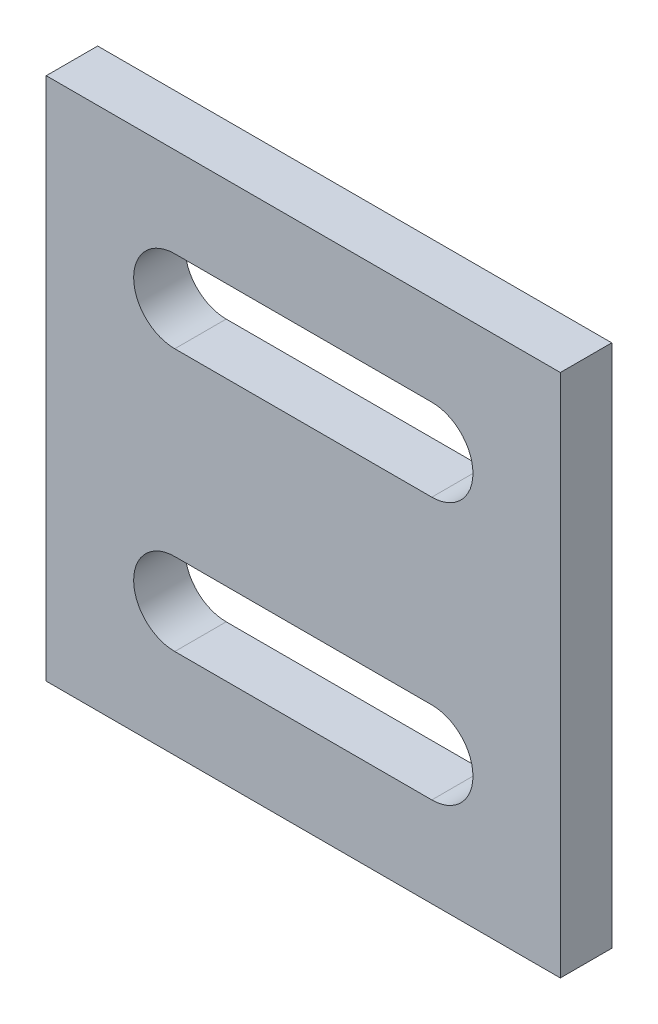
from build123d import *

# Parameters (mm, degrees)
SKETCH_1_W      = 20
SKETCH_1_H      = 20.4
EXTRUDE_1_DEPTH = 2


with BuildPart() as part:
    # 草图1 → 凸台-拉伸1 (new body)
    with BuildSketch(Plane.XY):
        with Locations((-8.175518001, 8.140962295)):
            Rectangle(SKETCH_1_W, SKETCH_1_H)
        with BuildLine():
            Line((-13.175518001, 14.840962295), (-3.175518001, 14.840962295))
            ThreePointArc((-3.175518001, 14.840962295), (-1.575518001, 13.240962295), (-3.175518001, 11.640962295))
            Line((-3.175518001, 11.640962295), (-13.175518001, 11.640962295))
            ThreePointArc((-13.175518001, 11.640962295), (-14.775518001, 13.240962295), (-13.175518001, 14.840962295))
        make_face(mode=Mode.SUBTRACT)
        with BuildLine():
            Line((-13.175518001, 1.440962295), (-3.175518001, 1.440962295))
            ThreePointArc((-3.175518001, 1.440962295), (-1.575518001, 3.040962295), (-3.175518001, 4.640962295))
            Line((-3.175518001, 4.640962295), (-13.175518001, 4.640962295))
            ThreePointArc((-13.175518001, 4.640962295), (-14.775518001, 3.040962295), (-13.175518001, 1.440962295))
        make_face(mode=Mode.SUBTRACT)
    extrude(amount=EXTRUDE_1_DEPTH)


solid = part.part
